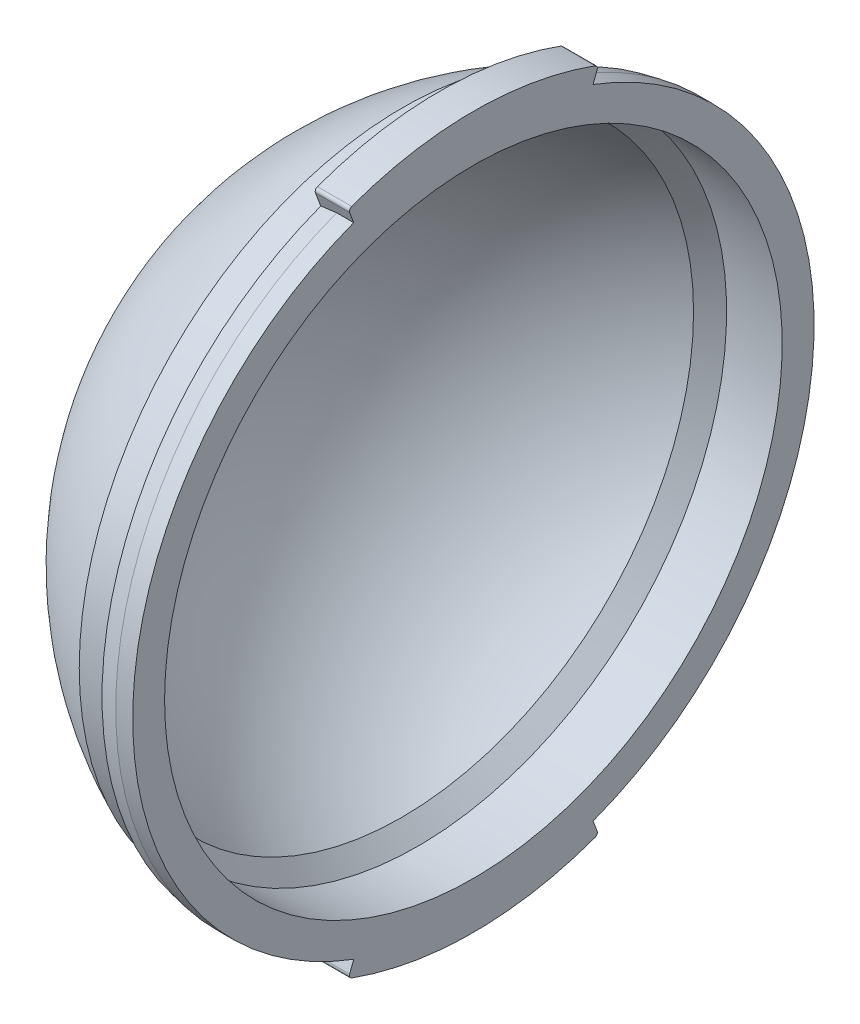
from build123d import *

# Parameters (mm, degrees)
BOSS_EXTRUDE2_DEPTH  = 5.1
FILLET1_R            = 0.5
FILLET1_OF_MIRROR1_R = 0.5


with BuildPart() as part:
    # Sketch1 → Revolve1 (revolve)
    with BuildSketch(Plane(origin=(0, 0, 0), x_dir=(1, 0, 0), z_dir=(0, 1, 0))):
        with BuildLine():
            Line((0, 46.0502), (-8.2931, 46.0502))
            Line((-8.2931, 46.0502), (-10.689645397, 43.517785789))
            ThreePointArc((-10.689645397, 43.517785789), (-30.34289905, 25.58829166), (-37.620018589, 0))
            Line((-37.620018589, 0), (-41.835987512, 0))
            ThreePointArc((-41.835987512, 0), (-33.320163486, 28.765773565), (-10.517441644, 48.26))
            Line((-10.517441644, 48.26), (-5.08, 48.26))
            Line((-5.08, 48.26), (-5.08, 50.3))
            Line((-5.08, 50.3), (-2.54, 50.8))
            Line((-2.54, 50.8), (0, 50.8))
            Line((0, 50.8), (0, 46.0502))
        make_face()
    revolve(axis=Axis((2.224514483, 0, 0), (1, 0, 0)))

    # Sketch3 → Boss-Extrude2 (add)
    with BuildSketch(Plane(origin=(0, 0, 0), x_dir=(0, 0, -1), z_dir=(1, 0, 0))):
        with BuildLine():
            Line((-16.873281471, 44.963240513), (-18.63, 49.644473257))
            ThreePointArc((-18.63, 49.644473257), (0, 53.025), (18.63, 49.644473257))
            Line((18.63, 49.644473257), (16.873281471, 44.963240513))
            ThreePointArc((16.873281471, 44.963240513), (0, 48.025), (-16.873281471, 44.963240513))
        make_face()
    boss_extrude2 = extrude(amount=-BOSS_EXTRUDE2_DEPTH)

    # Fillet1
    fillet1_edges = [part.edges().sort_by_distance(p)[0] for p in [
        (-2.55, 49.644473257, -18.63),
        (-2.55, 49.644473257, 18.63),
    ]]
    fillet(fillet1_edges, radius=FILLET1_R)

    # Mirror1: Boss-Extrude2 across plane
    add(boss_extrude2.mirror(Plane.ZX))

    # Fillet1 of Mirror1
    fillet1_of_mirror1_edges = [part.edges().sort_by_distance(p)[0] for p in [
        (-2.55, -49.644473257, -18.63),
        (-2.55, -49.644473257, 18.63),
    ]]
    fillet(fillet1_of_mirror1_edges, radius=FILLET1_OF_MIRROR1_R)


solid = part.part
